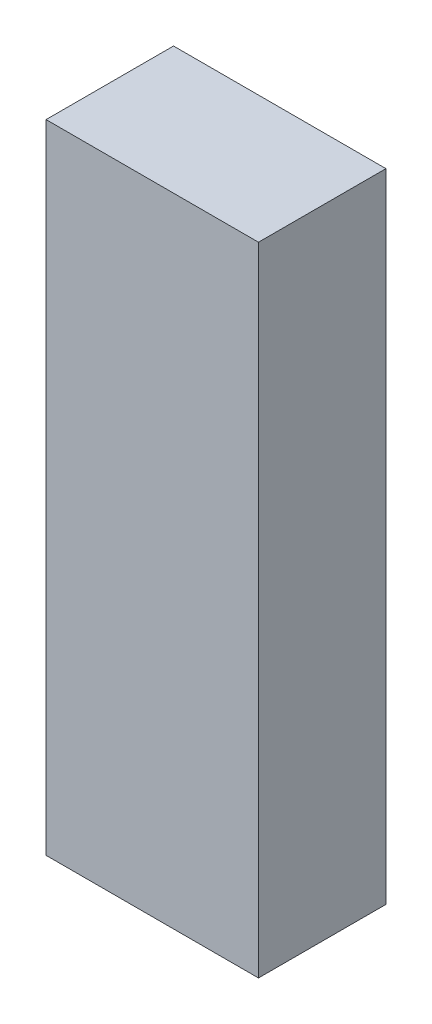
from build123d import *

# Parameters (mm, degrees)
SKETCH1_W           = 40
SKETCH1_H           = 120
BOSS_EXTRUDE1_DEPTH = 24


with BuildPart() as part:
    # Sketch1 → Boss-Extrude1 (new body)
    with BuildSketch(Plane.XY):
        with Locations((-293.749186861, 60)):
            Rectangle(SKETCH1_W, SKETCH1_H)
    extrude(amount=BOSS_EXTRUDE1_DEPTH)


solid = part.part
